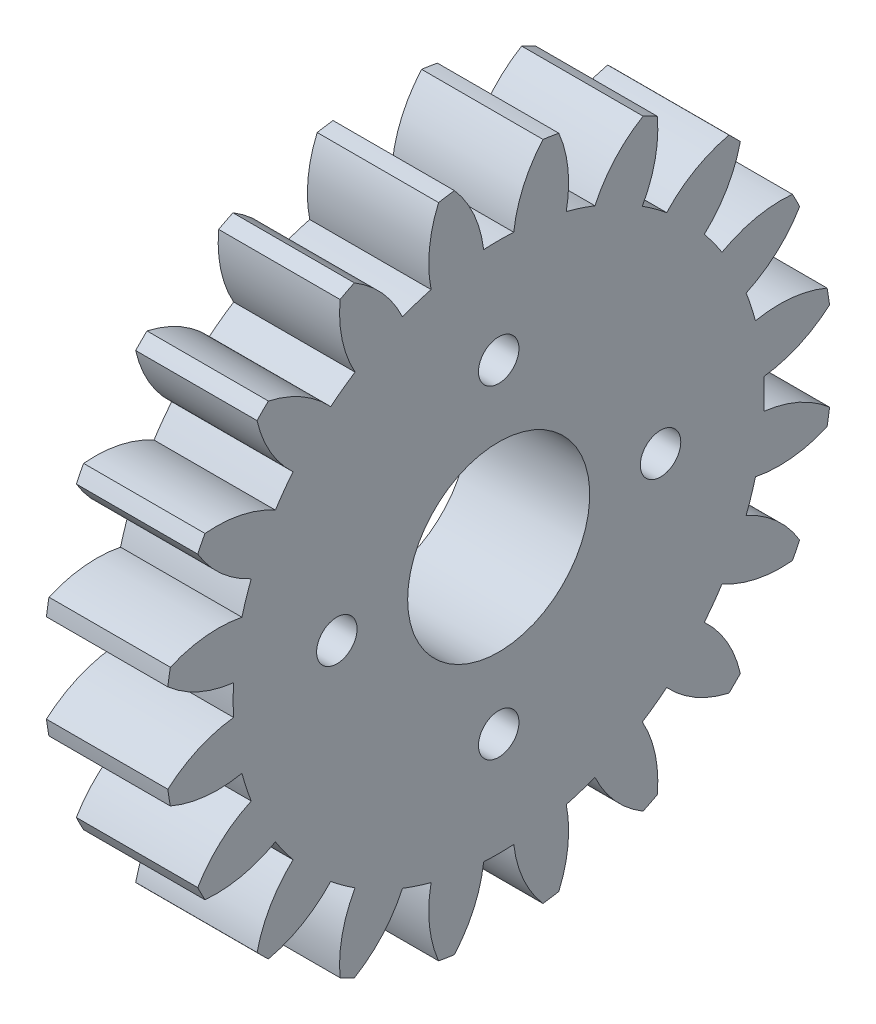
from build123d import *

# Parameters (mm, degrees)
BASPROSKE_W             = 6
BASPROSKE_H             = 16.5
TOOTHCUT_DEPTH          = 25.093567606
TEETHCUTS_COUNT         = 20
TEETHCUTS_ANGLE         = 342
BORSKE_R                = 4.5
BORE_DEPTH              = 50.0000508
ESQUISSE2_R             = 1
ENL_V_MAT_EXTRU_1_DEPTH = 6


with BuildPart() as part:
    # BasProSke → Base-Revolve (revolve)
    with BuildSketch(Plane(origin=(0, 0, 0), x_dir=(1, 0, 0), z_dir=(0, 1, 0)), mode=Mode.PRIVATE) as base_revolve_sk:
        with Locations((3, 8.25)):
            Rectangle(BASPROSKE_W, BASPROSKE_H)
    revolve(base_revolve_sk.sketch.rotate(Axis((-10, 0, 0), (1, 0, 0)), 180), axis=Axis((-10, 0, 0), (1, 0, 0)))

    # TooCutSke → ToothCut (cut, through all)
    with BuildSketch(Plane(origin=(0, 0, 0), x_dir=(0, 0, -1), z_dir=(1, 0, 0))):
        with BuildLine():
            ThreePointArc((0.74381438, 13.102904875), (0, 13.124), (-0.74381438, 13.102904875))
            ThreePointArc((-0.74381438, 13.102904875), (-1.226473103, 14.852072512), (-2.209965745, 16.376962373))
            ThreePointArc((-2.209965745, 16.376962373), (0, 16.5254), (2.209965745, 16.376962373))
            ThreePointArc((2.209965745, 16.376962373), (1.226473103, 14.852072512), (0.74381438, 13.102904875))
        make_face()
    toothcut = extrude(amount=TOOTHCUT_DEPTH, mode=Mode.SUBTRACT)

    # TeethCuts: ToothCut ×20 about axis
    teethcuts_axis = Axis((-10, 0, 0), (1, 0, 0))
    for i in range(1, TEETHCUTS_COUNT):
        add(toothcut.rotate(teethcuts_axis, i * TEETHCUTS_ANGLE / (TEETHCUTS_COUNT - 1)), mode=Mode.SUBTRACT)

    # BorSke → Bore (cut, symmetric)
    with BuildSketch(Plane(origin=(0, 0, 0), x_dir=(0, 0, -1), z_dir=(1, 0, 0))):
        with Locations(Location((0, 0, 0), (0, 0, 180))):
            Circle(BORSKE_R)
    extrude(amount=BORE_DEPTH, both=True, mode=Mode.SUBTRACT)

    # Esquisse2 → Enlèv. mat.-Extru.1 (cut)
    with BuildSketch(Plane(origin=(6, 0, 0), x_dir=(0, 0, -1), z_dir=(1, 0, 0))):
        with Locations((0, 8)):
            Circle(ESQUISSE2_R)
        with Locations((8, 0)):
            Circle(ESQUISSE2_R)
        with Locations((0, -8)):
            Circle(ESQUISSE2_R)
        with Locations((-8, 0)):
            Circle(ESQUISSE2_R)
    extrude(amount=-ENL_V_MAT_EXTRU_1_DEPTH, mode=Mode.SUBTRACT)


solid = part.part
